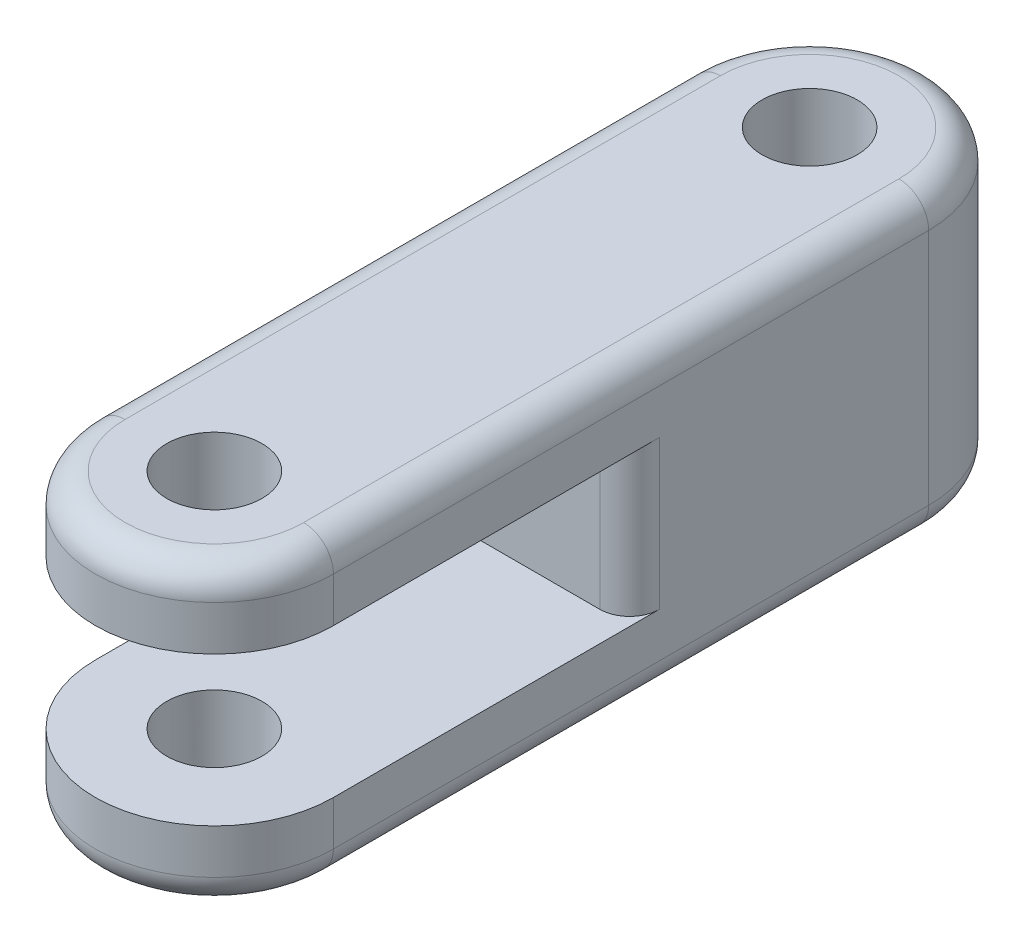
from build123d import *

# Parameters (mm, degrees)
SKETCH_1_R          = 1.6
EXTRUDE_1_DEPTH     = 10
SKETCH_2_W          = 19.899365944
SKETCH_2_H          = 5
CUT_EXTRUDE_1_DEPTH = 10
FILLET_1_R          = 1


with BuildPart() as part:
    # 草图1 → 凸台-拉伸1 (new body)
    with BuildSketch(Plane(origin=(0, 0, 0), x_dir=(1, 0, 0), z_dir=(0, 1, 0))):
        with BuildLine():
            Line((-4, 0), (-4, 20))
            ThreePointArc((-4, 20), (0, 24), (4, 20))
            Line((4, 20), (4, 0))
            ThreePointArc((4, 0), (0, -4), (-4, 0))
        make_face()
        with Locations((0, 20)):
            Circle(SKETCH_1_R, mode=Mode.SUBTRACT)
        Circle(SKETCH_1_R, mode=Mode.SUBTRACT)
    extrude(amount=EXTRUDE_1_DEPTH)

    # 草图2 → 切除-拉伸1 (cut)
    with BuildSketch(Plane(origin=(4, 0, 0), x_dir=(0, 0, -1), z_dir=(1, 0, 0))):
        with Locations((0, 5)):
            Rectangle(SKETCH_2_W, SKETCH_2_H)
    extrude(amount=-CUT_EXTRUDE_1_DEPTH, mode=Mode.SUBTRACT)

    # 圆角1
    fillet_1_edges = [part.edges().sort_by_distance(p)[0] for p in [
        (4, 10, -10),
        (0, 10, -24),
        (-4, 5, -9.949682972),
        (-4, 10, -10),
        (4, 5, -9.949682972),
        (0, 10, 4),
        (0, 0, 4),
        (-4, 0, -10),
        (0, 0, -24),
        (4, 0, -10),
    ]]
    fillet(fillet_1_edges, radius=FILLET_1_R)


solid = part.part
